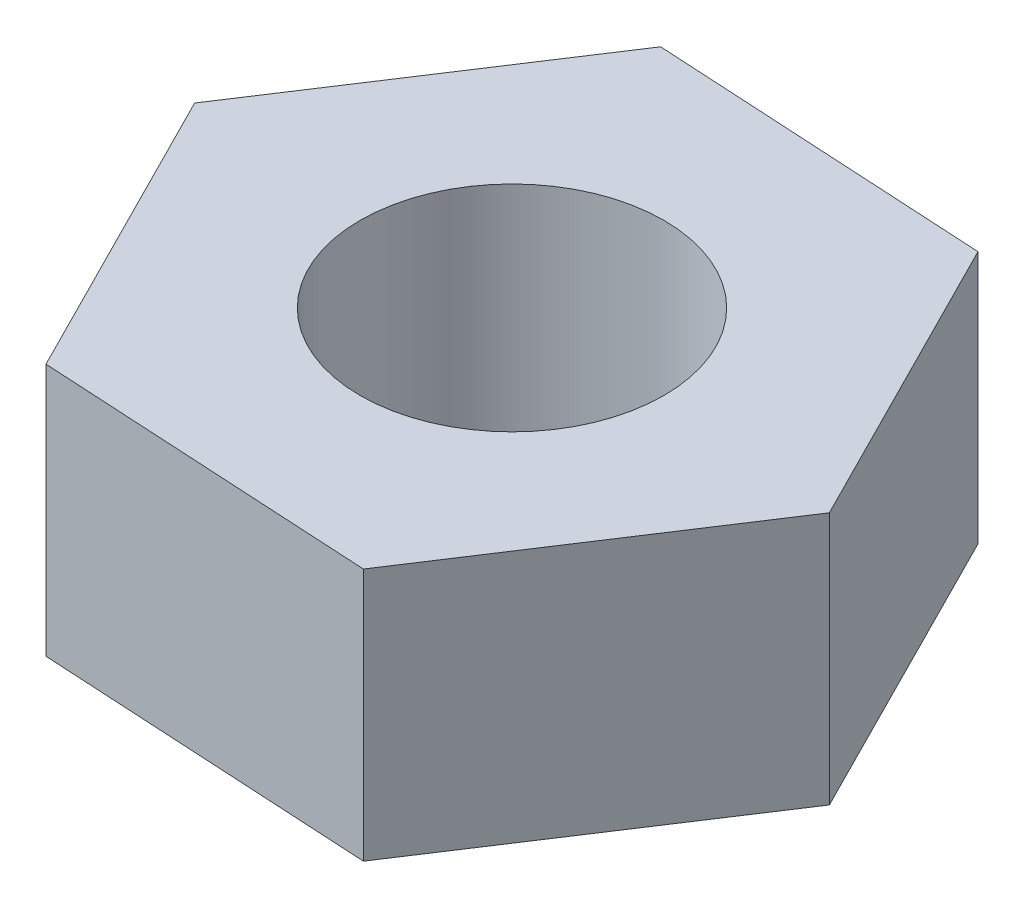
from build123d import *

# Parameters (mm, degrees)
SKETCH1_R           = 1.5
BOSS_EXTRUDE1_DEPTH = 2.5


with BuildPart() as part:
    # Sketch1 → Boss-Extrude1 (new body)
    with BuildSketch(Plane(origin=(0, 0, 0), x_dir=(1, 0, 0), z_dir=(0, 1, 0))):
        Polygon((-3.320881253, 0.185260878), (-1.820881253, -2.783337089), (1.5, -2.968597967), (3.320881253, -0.185260878), (1.820881253, 2.783337089), (-1.5, 2.968597967), align=None)
        Circle(SKETCH1_R, mode=Mode.SUBTRACT)
    extrude(amount=BOSS_EXTRUDE1_DEPTH)


solid = part.part
